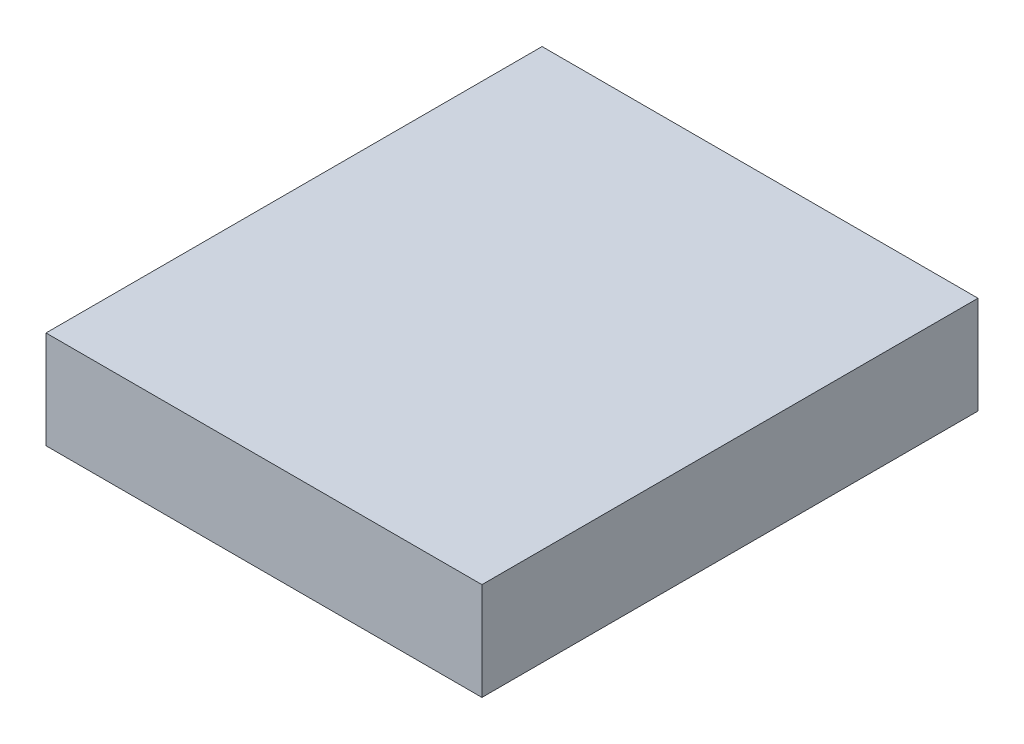
from build123d import *

# Parameters (mm, degrees)
SKETCH1_W           = 736.6
SKETCH1_H           = 838.2
BOSS_EXTRUDE1_DEPTH = 165.1


with BuildPart() as part:
    # Sketch1 → Boss-Extrude1 (new body)
    with BuildSketch(Plane(origin=(0, 0, 0), x_dir=(1, 0, 0), z_dir=(0, 1, 0))):
        with Locations((368.3, 419.1)):
            Rectangle(SKETCH1_W, SKETCH1_H)
    extrude(amount=BOSS_EXTRUDE1_DEPTH)


solid = part.part
